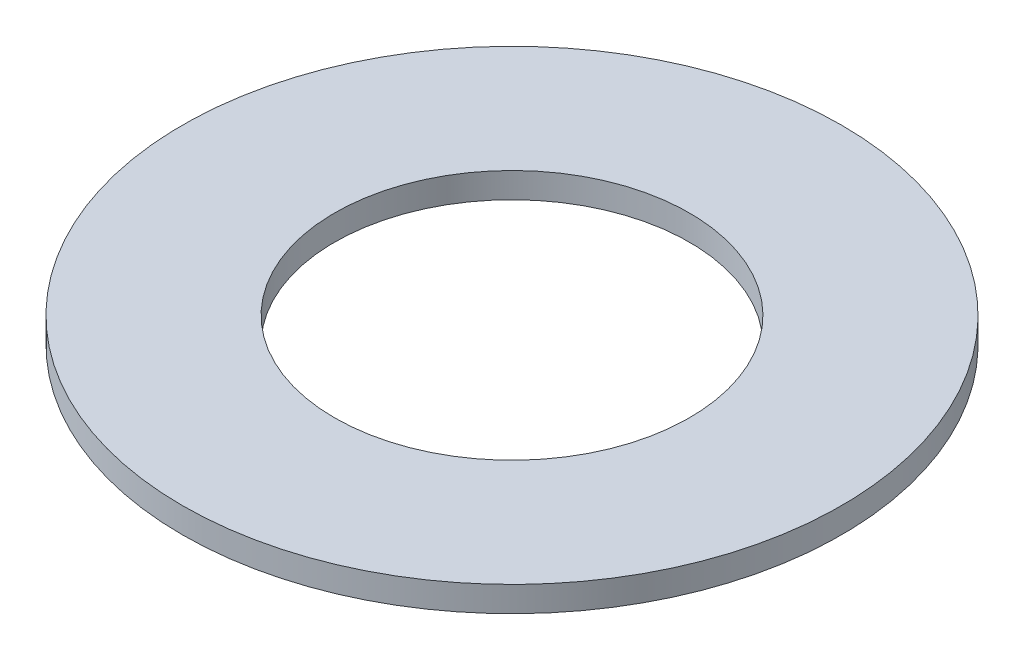
from build123d import *

# Parameters (mm, degrees)
SKETCH2_R           = 130
SKETCH2_R_2         = 70
BOSS_EXTRUDE1_DEPTH = 10


with BuildPart() as part:
    # Sketch2 → Boss-Extrude1 (new body)
    with BuildSketch(Plane(origin=(0, 0, 0), x_dir=(1, 0, 0), z_dir=(0, 1, 0))):
        Circle(SKETCH2_R)
        Circle(SKETCH2_R_2, mode=Mode.SUBTRACT)
    extrude(amount=BOSS_EXTRUDE1_DEPTH)


solid = part.part
